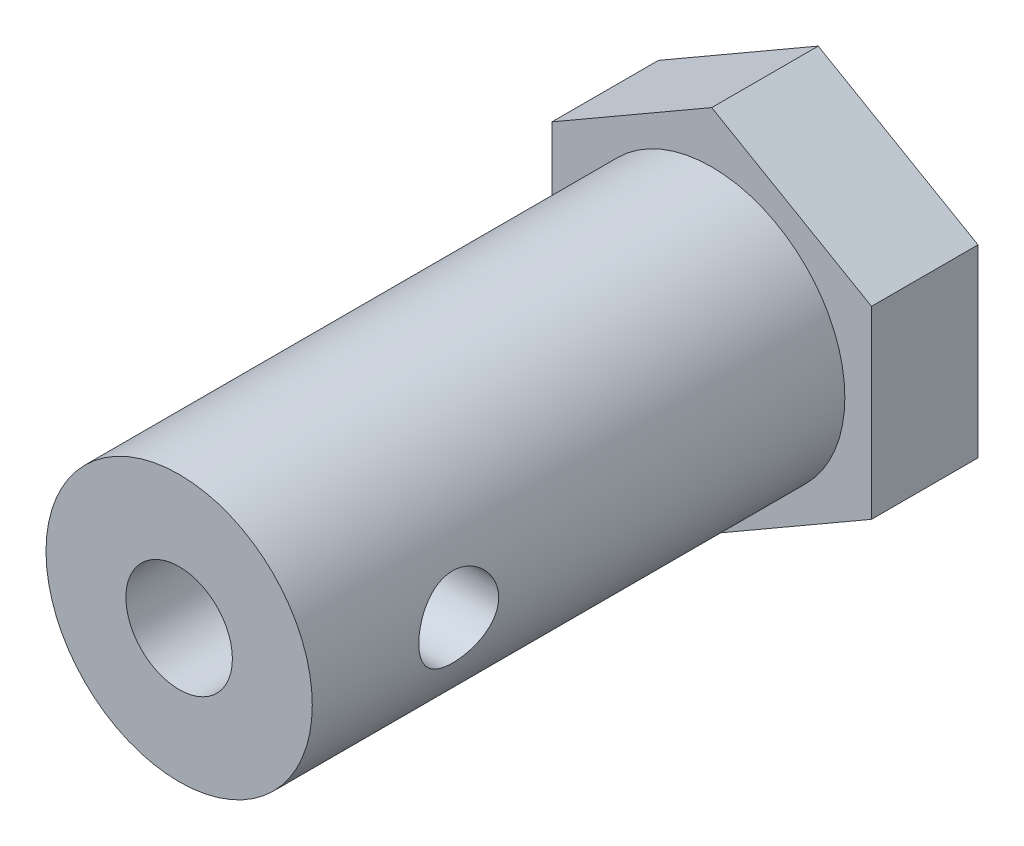
from build123d import *

# Parameters (mm, degrees)
BOSS_EXTRUDE1_DEPTH = 4
SKETCH2_R           = 5
BOSS_EXTRUDE2_DEPTH = 20
SKETCH3_R           = 2
CUT_EXTRUDE1_DEPTH  = 10
SKETCH4_R           = 1.5
CUT_EXTRUDE2_DEPTH  = 7
SKETCH5_R           = 1.5
CUT_EXTRUDE3_DEPTH  = 10


with BuildPart() as part:
    # Sketch1 → Boss-Extrude1 (new body)
    with BuildSketch(Plane.XY):
        Polygon((0, 6.92820323), (-6, 3.464101615), (-6, -3.464101615), (0, -6.92820323), (6, -3.464101615), (6, 3.464101615), align=None)
    extrude(amount=BOSS_EXTRUDE1_DEPTH)

    # Sketch2 → Boss-Extrude2 (add)
    with BuildSketch(Plane.XY.offset(4)):
        Circle(SKETCH2_R)
    extrude(amount=BOSS_EXTRUDE2_DEPTH)

    # Sketch3 → Cut-Extrude1 (cut)
    with BuildSketch(Plane.XY.offset(24)):
        Circle(SKETCH3_R)
    extrude(amount=-CUT_EXTRUDE1_DEPTH, mode=Mode.SUBTRACT)

    # Sketch4 → Cut-Extrude2 (cut)
    with BuildSketch(Plane(origin=(0, 0, 0), x_dir=(0, 0, -1), z_dir=(1, 0, 0))):
        with Locations((-18.5, 0)):
            Circle(SKETCH4_R)
    extrude(amount=CUT_EXTRUDE2_DEPTH, mode=Mode.SUBTRACT)

    # Sketch5 → Cut-Extrude3 (cut)
    with BuildSketch(Plane(origin=(0, 0, 0), x_dir=(-1, 0, 0), z_dir=(0, 0, -1))):
        Circle(SKETCH5_R)
    extrude(amount=-CUT_EXTRUDE3_DEPTH, mode=Mode.SUBTRACT)


solid = part.part
